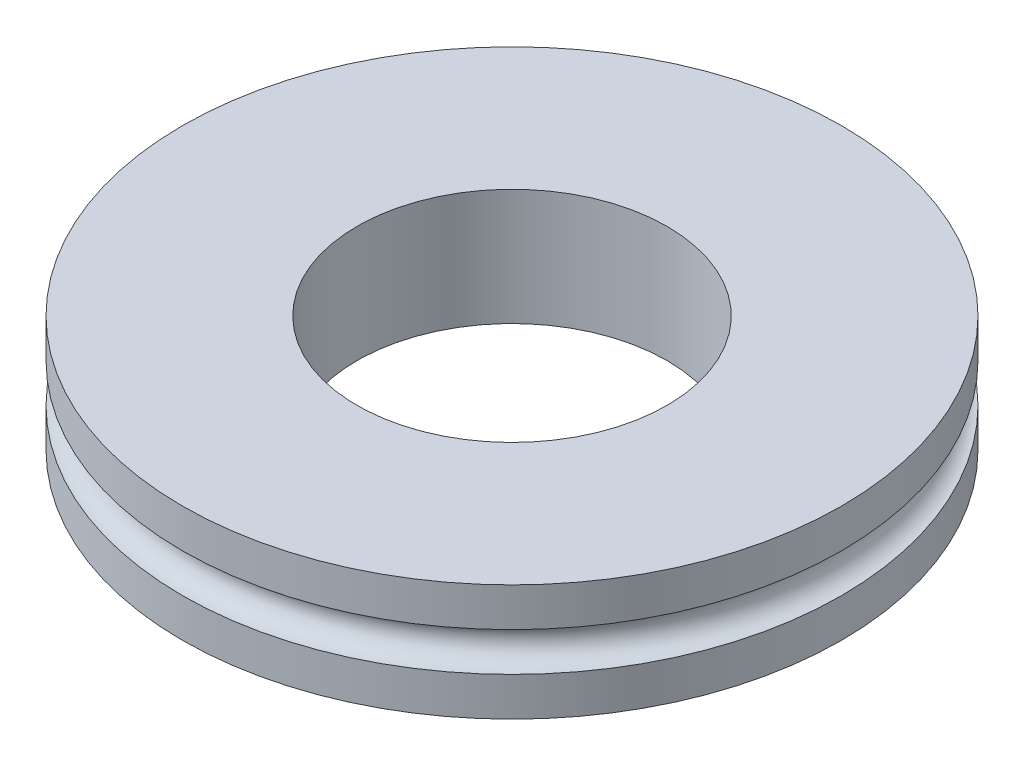
from build123d import *


with BuildPart() as part:
    # Sketch1 → Revolve1 (revolve)
    with BuildSketch(Plane.XY):
        with BuildLine():
            Line((4, 1.5), (4, -1.5))
            Line((4, -1.5), (8.5, -1.5))
            Line((8.5, -1.5), (8.5, -0.5))
            ThreePointArc((8.5, -0.5), (8, 0), (8.5, 0.5))
            Line((8.5, 0.5), (8.5, 1.5))
            Line((8.5, 1.5), (4, 1.5))
        make_face()
    revolve(axis=Axis((0, -1.5, 0), (0, 1, 0)))


solid = part.part
